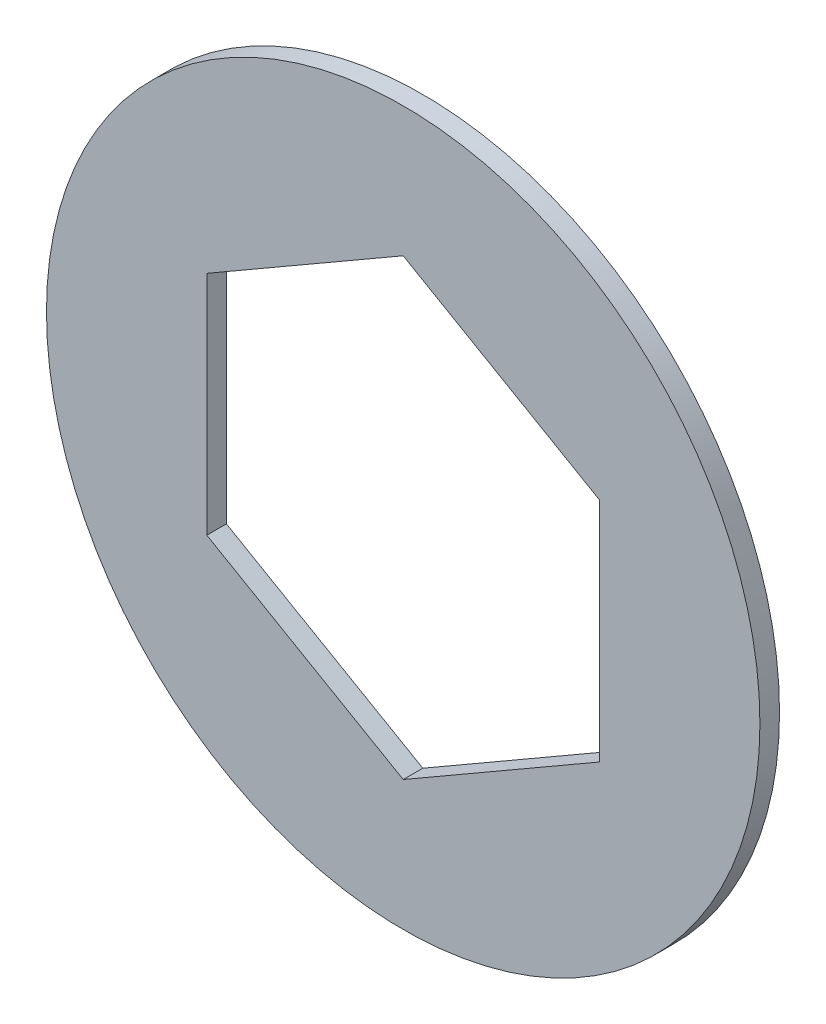
from build123d import *

# Parameters (mm, degrees)
ESQUISSE1_R        = 45.5
BOSS_EXTRU_1_DEPTH = 2.5


with BuildPart() as part:
    # Esquisse1 → Boss.-Extru.1 (new body)
    with BuildSketch(Plane.XY):
        Circle(ESQUISSE1_R)
        Polygon((0, 28.925248486), (-25.05, 14.462624243), (-25.05, -14.462624243), (0, -28.925248486), (25.05, -14.462624243), (25.05, 14.462624243), align=None, mode=Mode.SUBTRACT)
    extrude(amount=BOSS_EXTRU_1_DEPTH)


solid = part.part
